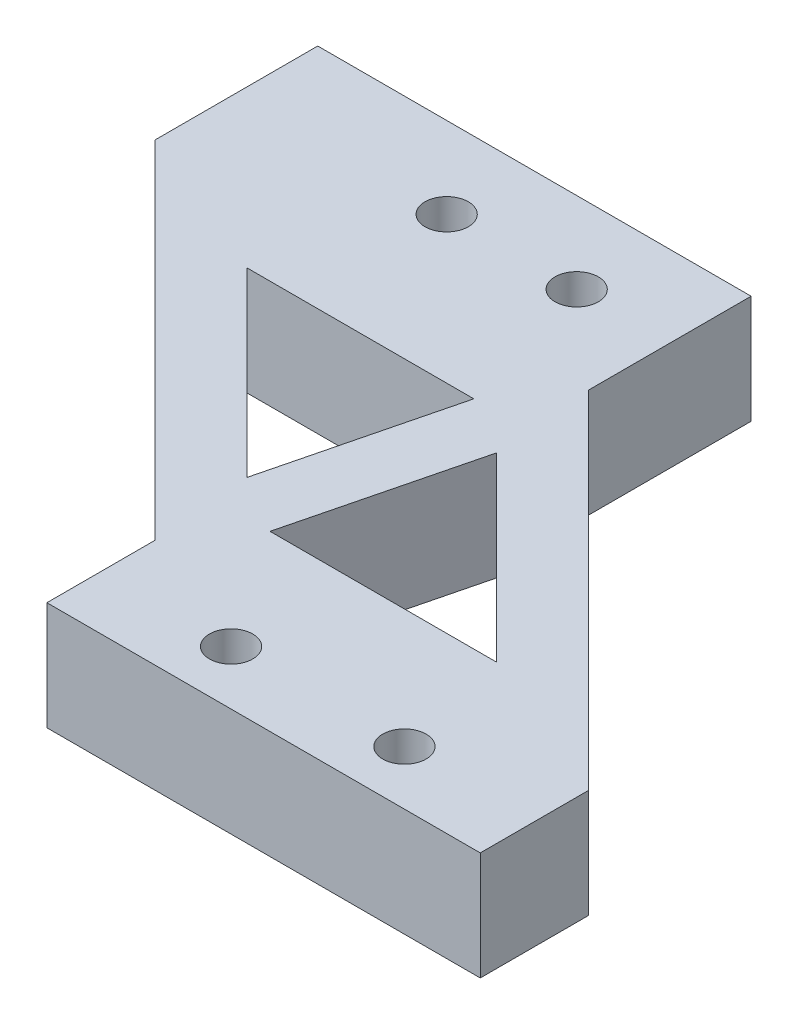
from build123d import *

# Parameters (mm, degrees)
BOSS_EXTRUDE1_DEPTH = 5
SKETCH2_W           = 20
SKETCH2_H           = 5
BOSS_EXTRUDE2_DEPTH = 7.5
SKETCH3_W           = 20
SKETCH3_H           = 5
BOSS_EXTRUDE3_DEPTH = 5
CUT_EXTRUDE2_REACH  = 7
CUT_EXTRUDE3_REACH  = 7
SKETCH7_R           = 1
CUT_EXTRUDE4_REACH  = 7
SKETCH8_R           = 1


with BuildPart() as part:
    # Sketch1 → Boss-Extrude1 (new body)
    with BuildSketch(Plane(origin=(0, 0, 0), x_dir=(1, 0, 0), z_dir=(0, 1, 0))):
        Polygon((-37.172745284, 27.474605058), (-17.172745284, 27.474605058), (-1.172745284, 11.474605058), (-21.172745284, 11.474605058), align=None)
    extrude(amount=BOSS_EXTRUDE1_DEPTH)

    # Sketch2 → Boss-Extrude2 (add)
    with BuildSketch(Plane(origin=(0, 0, -27.474605058), x_dir=(-1, 0, 0), z_dir=(0, 0, -1))):
        with Locations((27.172745284, 2.5)):
            Rectangle(SKETCH2_W, SKETCH2_H)
    extrude(amount=BOSS_EXTRUDE2_DEPTH)

    # Sketch3 → Boss-Extrude3 (add)
    with BuildSketch(Plane.XY.offset(-11.474605058)):
        with Locations((-11.172745284, 2.5)):
            Rectangle(SKETCH3_W, SKETCH3_H)
    extrude(amount=BOSS_EXTRUDE3_DEPTH)

    # Sketch5 → Cut-Extrude2 (cut, up to next)
    with BuildSketch(Plane(origin=(0, 5, 0), x_dir=(1, 0, 0), z_dir=(0, 1, 0)), mode=Mode.PRIVATE) as cut_extrude2_sk1:
        Polygon((-16.784341734, 22.843560821), (-8.415385971, 14.474605058), (-18.876580675, 14.474605058), align=None)
    cut_extrude2_tool1 = extrude(cut_extrude2_sk1.sketch, amount=-CUT_EXTRUDE2_REACH, mode=Mode.PRIVATE) & part.part
    add(cut_extrude2_tool1.solids().sort_by_distance((-14.692103, 5, -17.264257))[0], mode=Mode.SUBTRACT)
    # Sketch5 → Cut-Extrude2 (cut, up to next)
    with BuildSketch(Plane(origin=(0, 5, 0), x_dir=(1, 0, 0), z_dir=(0, 1, 0)), mode=Mode.PRIVATE) as cut_extrude2_sk2:
        Polygon((-21.561148834, 16.105649296), (-29.930104597, 24.474605058), (-19.468909894, 24.474605058), align=None)
    cut_extrude2_tool2 = extrude(cut_extrude2_sk2.sketch, amount=-CUT_EXTRUDE2_REACH, mode=Mode.PRIVATE) & part.part
    add(cut_extrude2_tool2.solids().sort_by_distance((-23.653388, 5, -21.684953))[0], mode=Mode.SUBTRACT)

    # Sketch7 → Cut-Extrude3 (cut, up to next)
    with BuildSketch(Plane(origin=(0, 5, 0), x_dir=(1, 0, 0), z_dir=(0, 1, 0)), mode=Mode.PRIVATE) as cut_extrude3_sk1:
        with Locations((-15.172745284, 8.974605058)):
            Circle(SKETCH7_R)
    cut_extrude3_tool1 = extrude(cut_extrude3_sk1.sketch, amount=-CUT_EXTRUDE3_REACH, mode=Mode.PRIVATE) & part.part
    add(cut_extrude3_tool1.solids().sort_by_distance((-15.172745, 5, -8.974605))[0], mode=Mode.SUBTRACT)
    # Sketch7 → Cut-Extrude3 (cut, up to next)
    with BuildSketch(Plane(origin=(0, 5, 0), x_dir=(1, 0, 0), z_dir=(0, 1, 0)), mode=Mode.PRIVATE) as cut_extrude3_sk2:
        with Locations((-7.172745284, 8.974605058)):
            Circle(SKETCH7_R)
    cut_extrude3_tool2 = extrude(cut_extrude3_sk2.sketch, amount=-CUT_EXTRUDE3_REACH, mode=Mode.PRIVATE) & part.part
    add(cut_extrude3_tool2.solids().sort_by_distance((-7.172745, 5, -8.974605))[0], mode=Mode.SUBTRACT)

    # Sketch8 → Cut-Extrude4 (cut, up to next)
    with BuildSketch(Plane(origin=(0, 5, 0), x_dir=(1, 0, 0), z_dir=(0, 1, 0)), mode=Mode.PRIVATE) as cut_extrude4_sk1:
        with Locations((-21.472745284, 31.224605058)):
            Circle(SKETCH8_R)
    cut_extrude4_tool1 = extrude(cut_extrude4_sk1.sketch, amount=-CUT_EXTRUDE4_REACH, mode=Mode.PRIVATE) & part.part
    add(cut_extrude4_tool1.solids().sort_by_distance((-21.472745, 5, -31.224605))[0], mode=Mode.SUBTRACT)
    # Sketch8 → Cut-Extrude4 (cut, up to next)
    with BuildSketch(Plane(origin=(0, 5, 0), x_dir=(1, 0, 0), z_dir=(0, 1, 0)), mode=Mode.PRIVATE) as cut_extrude4_sk2:
        with Locations((-27.472745284, 31.224605058)):
            Circle(SKETCH8_R)
    cut_extrude4_tool2 = extrude(cut_extrude4_sk2.sketch, amount=-CUT_EXTRUDE4_REACH, mode=Mode.PRIVATE) & part.part
    add(cut_extrude4_tool2.solids().sort_by_distance((-27.472745, 5, -31.224605))[0], mode=Mode.SUBTRACT)


solid = part.part
